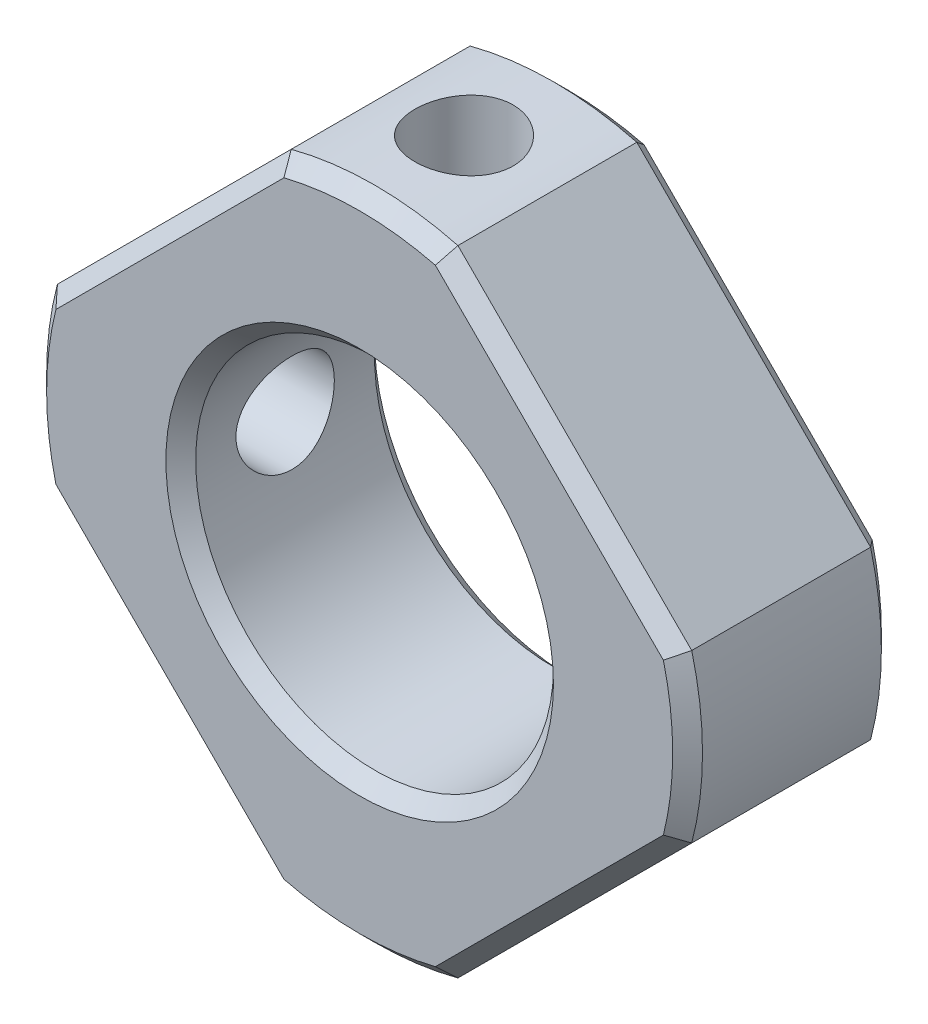
from build123d import *

# Parameters (mm, degrees)
SKETCH1_R           = 6
BOSS_EXTRUDE1_DEPTH = 3.5
SKETCH2_OUTSIDE_W   = 36.598
SKETCH2_OUTSIDE_H   = 36.598
SKETCH2_OUTSIDE_R   = 11
CUT_EXTRUDE1_DEPTH  = 8
SKETCH4_R           = 1.65
CUT_EXTRUDE2_DEPTH  = 12
SKETCH5_R           = 1.65
CUT_EXTRUDE3_DEPTH  = 12
CHAMFER1_SIZE       = 0.5


with BuildPart() as part:
    # Sketch1 → Boss-Extrude1 (new body, symmetric)
    with BuildSketch(Plane.XY):
        Polygon((0, -13.435028843), (-13.435028843, 0), (0, 13.435028843), (13.435028843, 0), align=None)
        Circle(SKETCH1_R, mode=Mode.SUBTRACT)
    extrude(amount=BOSS_EXTRUDE1_DEPTH, both=True)

    # Sketch2 outside → Cut-Extrude1 (cut, through all)
    with BuildSketch(Plane.XY.offset(3.5)):
        Rectangle(SKETCH2_OUTSIDE_W, SKETCH2_OUTSIDE_H)
        Circle(SKETCH2_OUTSIDE_R, mode=Mode.SUBTRACT)
    extrude(amount=-CUT_EXTRUDE1_DEPTH, mode=Mode.SUBTRACT)

    # Sketch4 → Cut-Extrude2 (cut, through all)
    with BuildSketch(Plane(origin=(0, 0, 0), x_dir=(1, 0, 0), z_dir=(0, 1, 0))):
        Circle(SKETCH4_R)
    extrude(amount=CUT_EXTRUDE2_DEPTH, mode=Mode.SUBTRACT)

    # Sketch5 → Cut-Extrude3 (cut, through all)
    with BuildSketch(Plane(origin=(0, 0, 0), x_dir=(0, 0, -1), z_dir=(1, 0, 0))):
        Circle(SKETCH5_R)
    extrude(amount=-CUT_EXTRUDE3_DEPTH, mode=Mode.SUBTRACT)

    # Chamfer1
    chamfer1_edges = [part.edges().sort_by_distance(p)[0] for p in [
        (-6, 0, -3.5),
        (-6, 0, 3.5),
        (6.717514421, 6.717514421, -3.5),
        (6.717514421, 6.717514421, 3.5),
        (6.717514421, -6.717514421, -3.5),
        (6.717514421, -6.717514421, 3.5),
        (-6.717514421, -6.717514421, -3.5),
        (-6.717514421, -6.717514421, 3.5),
        (-6.717514421, 6.717514421, -3.5),
        (-6.717514421, 6.717514421, 3.5),
        (-11, 0, -3.5),
        (0, -11, -3.5),
        (11, 0, -3.5),
        (0, 11, -3.5),
        (0, 11, 3.5),
        (-11, 0, 3.5),
        (0, -11, 3.5),
        (11, 0, 3.5),
    ]]
    chamfer(chamfer1_edges, length=CHAMFER1_SIZE)


solid = part.part
